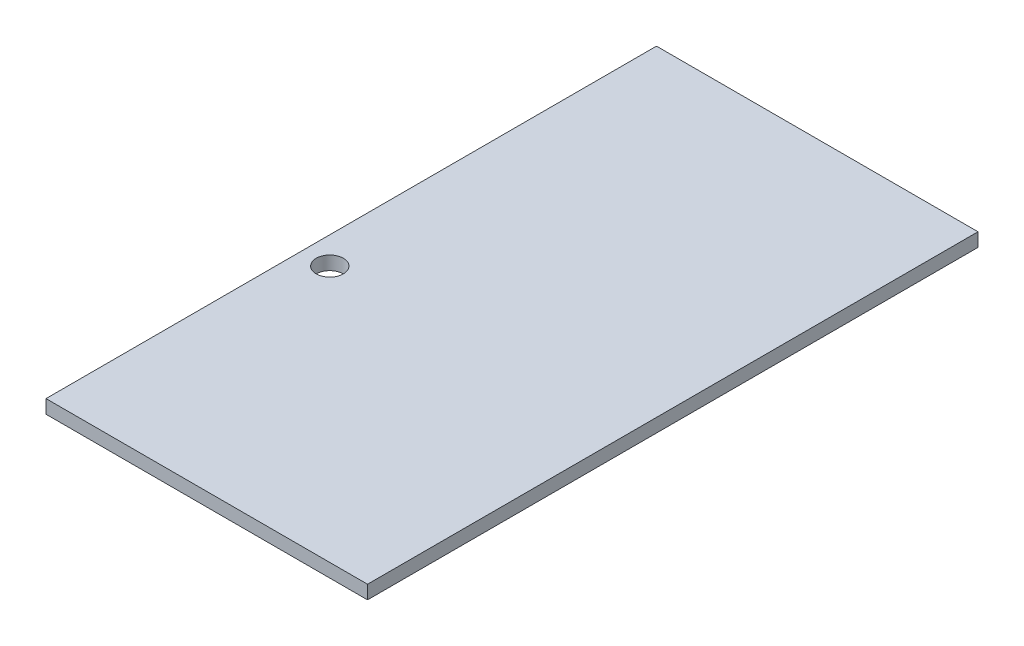
from build123d import *

# Parameters (mm, degrees)
CROQUIS1_W              = 237
CROQUIS1_H              = 450
SALIENTE_EXTRUIR1_DEPTH = 10
CROQUIS2_W              = 5
CROQUIS2_H              = 450
SALIENTE_EXTRUIR2_DEPTH = 70
CROQUIS3_R              = 2
CORTAR_EXTRUIR1_DEPTH   = 70
CROQUIS4_W              = 450
CROQUIS4_H              = 70
CORTAR_EXTRUIR2_DEPTH   = 10
CROQUIS5_R              = 10
CORTAR_EXTRUIR4_DEPTH   = 10


with BuildPart() as part:
    # Croquis1 → Saliente-Extruir1 (new body)
    with BuildSketch(Plane(origin=(0, 0, 0), x_dir=(1, 0, 0), z_dir=(0, 1, 0))):
        Rectangle(CROQUIS1_W, CROQUIS1_H)
    extrude(amount=SALIENTE_EXTRUIR1_DEPTH)

    # Croquis2 → Saliente-Extruir2 (add)
    with BuildSketch(Plane.XZ):
        with Locations((-116, 0)):
            Rectangle(CROQUIS2_W, CROQUIS2_H)
    extrude(amount=SALIENTE_EXTRUIR2_DEPTH)

    # Croquis3 → Cortar-Extruir1 (cut)
    with BuildSketch(Plane(origin=(-113.5, 0, 0), x_dir=(0, 0, -1), z_dir=(1, 0, 0))):
        with Locations((-215, -10)):
            Circle(CROQUIS3_R)
        with Locations((215, -10)):
            Circle(CROQUIS3_R)
        with Locations((215, -60)):
            Circle(CROQUIS3_R)
        with Locations((-215, -60)):
            Circle(CROQUIS3_R)
    extrude(amount=-CORTAR_EXTRUIR1_DEPTH, mode=Mode.SUBTRACT)

    # Croquis4 → Cortar-Extruir2 (cut)
    with BuildSketch(Plane(origin=(-113.5, 0, 0), x_dir=(0, 0, -1), z_dir=(1, 0, 0))):
        with Locations((0, -35)):
            Rectangle(CROQUIS4_W, CROQUIS4_H)
    extrude(amount=-CORTAR_EXTRUIR2_DEPTH, mode=Mode.SUBTRACT)

    # Croquis5 → Cortar-Extruir4 (cut)
    with BuildSketch(Plane.XZ):
        with Locations((-98.5, 35.8)):
            Circle(CROQUIS5_R)
    extrude(amount=-CORTAR_EXTRUIR4_DEPTH, mode=Mode.SUBTRACT)


solid = part.part
